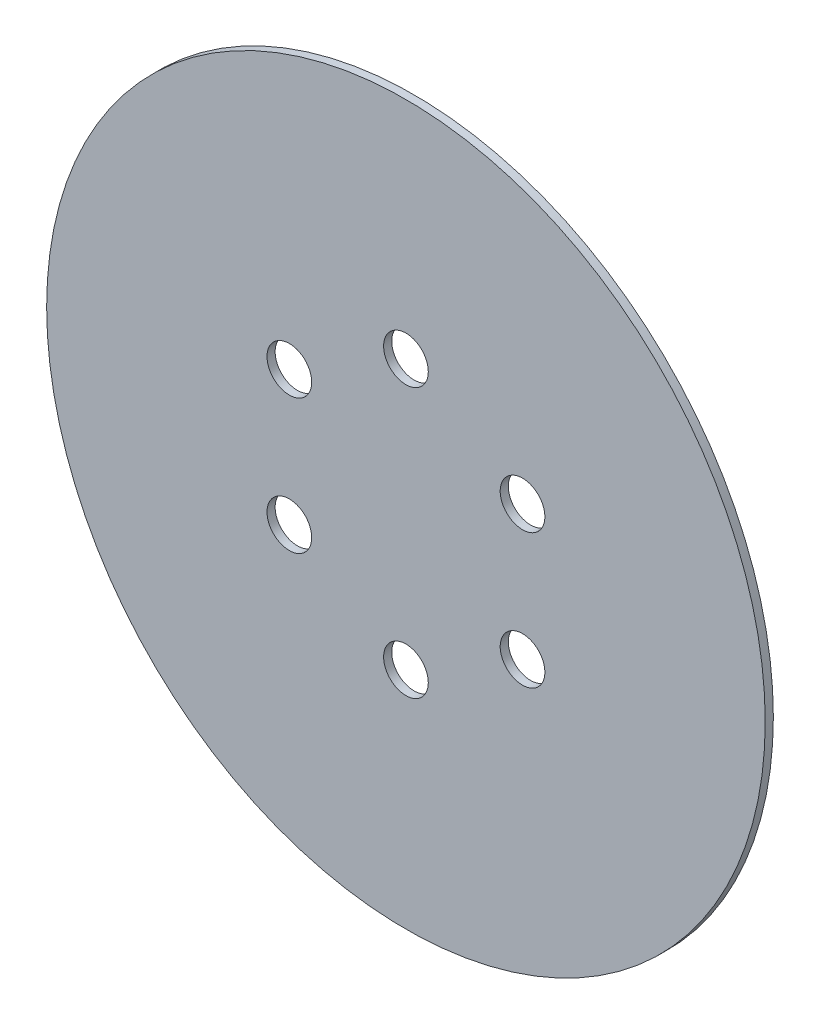
from build123d import *

# Parameters (mm, degrees)
SKETCH1_R           = 44.22
SKETCH1_R_2         = 2.75
BOSS_EXTRUDE1_DEPTH = 1


with BuildPart() as part:
    # Sketch1 → Boss-Extrude1 (new body)
    with BuildSketch(Plane.XY):
        with Locations((0, 1.049337112)):
            Circle(SKETCH1_R)
        with Locations((0, 17.619337112)):
            Circle(SKETCH1_R_2, mode=Mode.SUBTRACT)
        with Locations((14.350040941, 9.334337112)):
            Circle(SKETCH1_R_2, mode=Mode.SUBTRACT)
        with Locations((14.350040941, -7.235662888)):
            Circle(SKETCH1_R_2, mode=Mode.SUBTRACT)
        with Locations((0, -15.520662888)):
            Circle(SKETCH1_R_2, mode=Mode.SUBTRACT)
        with Locations((-14.350040941, -7.235662888)):
            Circle(SKETCH1_R_2, mode=Mode.SUBTRACT)
        with Locations((-14.350040941, 9.334337112)):
            Circle(SKETCH1_R_2, mode=Mode.SUBTRACT)
    extrude(amount=BOSS_EXTRUDE1_DEPTH)


solid = part.part
